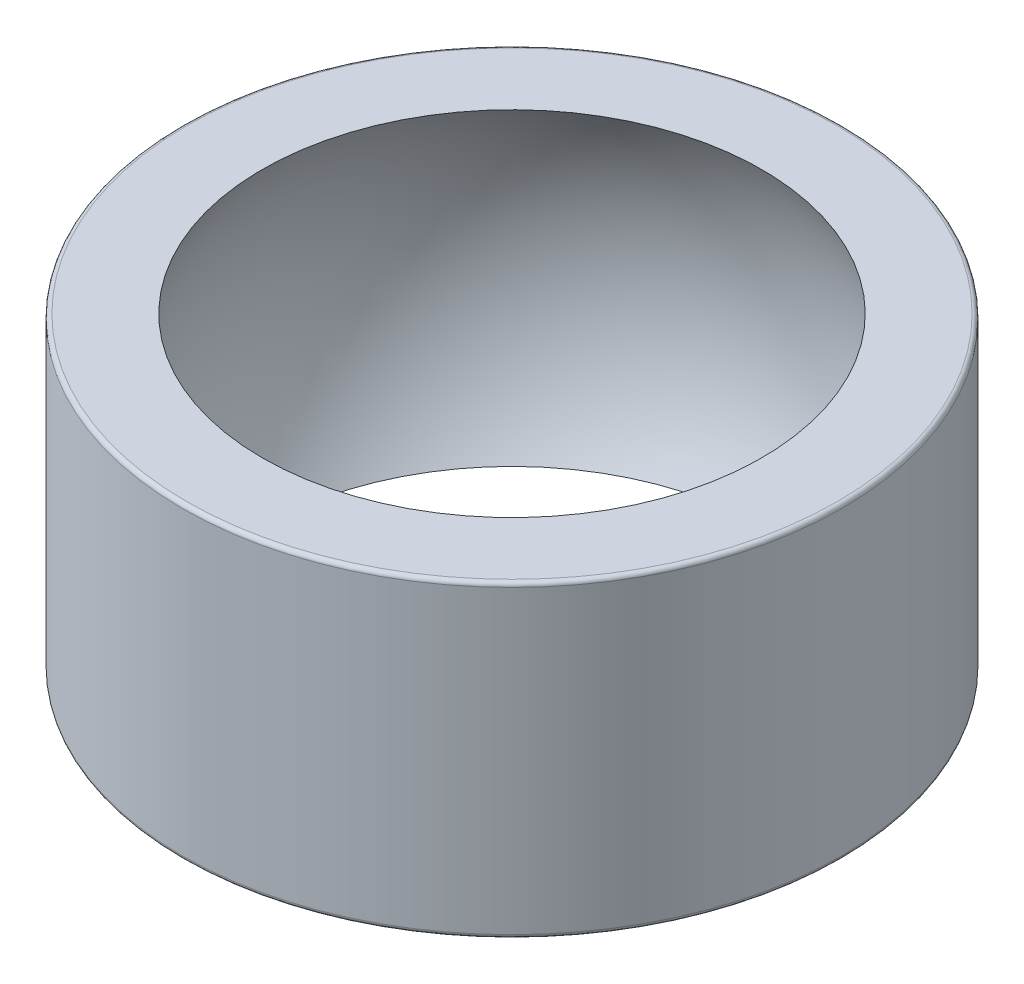
from build123d import *

# Parameters (mm, degrees)
SZKIC1_R                    = 16
DODANIE_WYCI_GNI_CIE1_DEPTH = 7.5
ZAOKR_GLENIE1_R             = 0.2


with BuildPart() as part:
    # Szkic1 → Dodanie-wyciągnięcie1 (new body, symmetric)
    with BuildSketch(Plane(origin=(0, 0, 0), x_dir=(1, 0, 0), z_dir=(0, 1, 0))):
        Circle(SZKIC1_R)
    extrude(amount=DODANIE_WYCI_GNI_CIE1_DEPTH, both=True)

    # Szkic3 → Wycięcie-obrót1 (revolve, cut)
    with BuildSketch(Plane.XY):
        with BuildLine():
            Line((0, -14.26), (0, 14.26))
            ThreePointArc((0, 14.26), (14.26, 0), (0, -14.26))
        make_face()
    revolve(axis=Axis((0, -14.26, 0), (0, 1, 0)), mode=Mode.SUBTRACT)

    # Zaokrąglenie1
    zaokr_glenie1_edges = [part.edges().sort_by_distance(p)[0] for p in [
        (-16, -7.5, 0),
        (-16, 7.5, 0),
    ]]
    fillet(zaokr_glenie1_edges, radius=ZAOKR_GLENIE1_R)


solid = part.part
